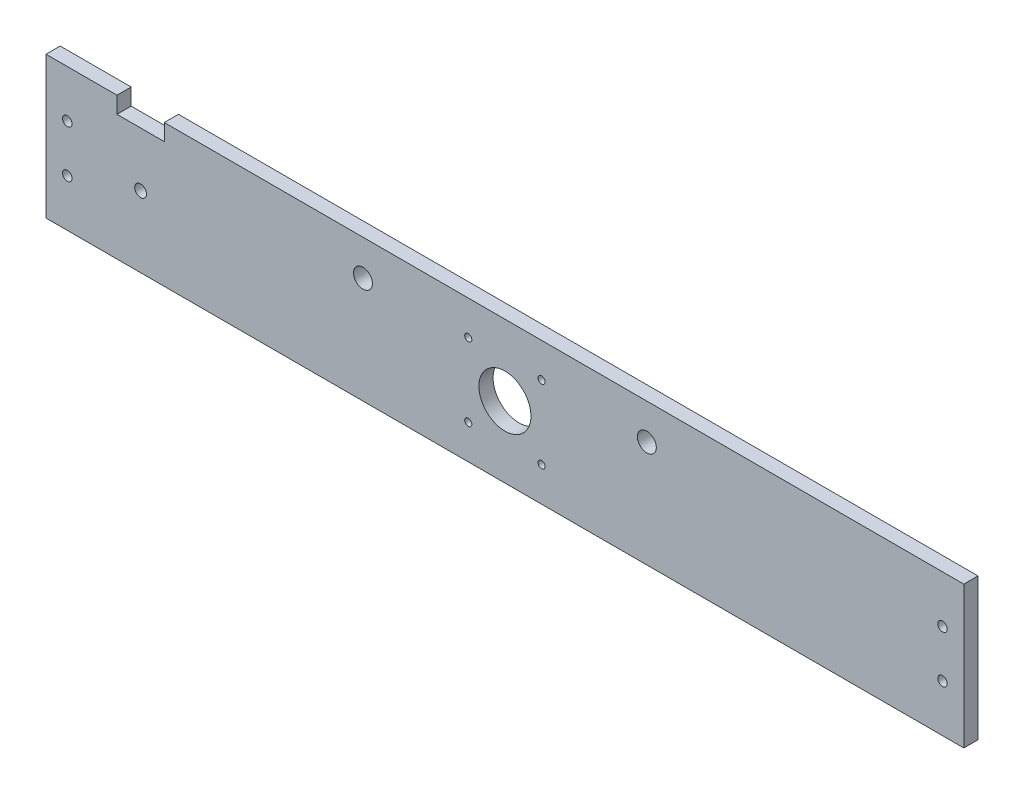
from build123d import *

# Parameters (mm, degrees)
SKETCH1_R           = 2
SKETCH1_R_2         = 2.5
SKETCH1_R_3         = 4
SKETCH1_R_4         = 11
BOSS_EXTRUDE1_DEPTH = 6
CUT_EXTRUDE1_REACH  = 8
SKETCH2_R           = 1.5


with BuildPart() as part:
    # Sketch1 → Boss-Extrude1 (new body)
    with BuildSketch(Plane.XY):
        Polygon((-194, 30), (-194, -30), (194, -30), (194, 30), (-144, 30), (-144, 23), (-164, 23), (-164, 30), align=None)
        with Locations((-185, -10)):
            Circle(SKETCH1_R, mode=Mode.SUBTRACT)
        with Locations((185, -10)):
            Circle(SKETCH1_R, mode=Mode.SUBTRACT)
        with Locations((-154, 0)):
            Circle(SKETCH1_R_2, mode=Mode.SUBTRACT)
        with Locations((-185, 10)):
            Circle(SKETCH1_R, mode=Mode.SUBTRACT)
        with Locations((-60, 15)):
            Circle(SKETCH1_R_3, mode=Mode.SUBTRACT)
        Circle(SKETCH1_R_4, mode=Mode.SUBTRACT)
        with Locations((60, 15)):
            Circle(SKETCH1_R_3, mode=Mode.SUBTRACT)
        with Locations((185, 10)):
            Circle(SKETCH1_R, mode=Mode.SUBTRACT)
    extrude(amount=BOSS_EXTRUDE1_DEPTH)

    # Sketch2 → Cut-Extrude1 (cut, up to next)
    with BuildSketch(Plane.XY.offset(6), mode=Mode.PRIVATE) as cut_extrude1_sk1:
        with Locations((15.495, 15.495)):
            Circle(SKETCH2_R)
    cut_extrude1_tool1 = extrude(cut_extrude1_sk1.sketch, amount=-CUT_EXTRUDE1_REACH, mode=Mode.PRIVATE) & part.part
    add(cut_extrude1_tool1.solids().sort_by_distance((15.495, 15.495, 6))[0], mode=Mode.SUBTRACT)
    # Sketch2 → Cut-Extrude1 (cut, up to next)
    with BuildSketch(Plane.XY.offset(6), mode=Mode.PRIVATE) as cut_extrude1_sk2:
        with Locations((-15.495, 15.495)):
            Circle(SKETCH2_R)
    cut_extrude1_tool2 = extrude(cut_extrude1_sk2.sketch, amount=-CUT_EXTRUDE1_REACH, mode=Mode.PRIVATE) & part.part
    add(cut_extrude1_tool2.solids().sort_by_distance((-15.495, 15.495, 6))[0], mode=Mode.SUBTRACT)
    # Sketch2 → Cut-Extrude1 (cut, up to next)
    with BuildSketch(Plane.XY.offset(6), mode=Mode.PRIVATE) as cut_extrude1_sk3:
        with Locations((15.495, -15.495)):
            Circle(SKETCH2_R)
    cut_extrude1_tool3 = extrude(cut_extrude1_sk3.sketch, amount=-CUT_EXTRUDE1_REACH, mode=Mode.PRIVATE) & part.part
    add(cut_extrude1_tool3.solids().sort_by_distance((15.495, -15.495, 6))[0], mode=Mode.SUBTRACT)
    # Sketch2 → Cut-Extrude1 (cut, up to next)
    with BuildSketch(Plane.XY.offset(6), mode=Mode.PRIVATE) as cut_extrude1_sk4:
        with Locations((-15.495, -15.495)):
            Circle(SKETCH2_R)
    cut_extrude1_tool4 = extrude(cut_extrude1_sk4.sketch, amount=-CUT_EXTRUDE1_REACH, mode=Mode.PRIVATE) & part.part
    add(cut_extrude1_tool4.solids().sort_by_distance((-15.495, -15.495, 6))[0], mode=Mode.SUBTRACT)


solid = part.part
